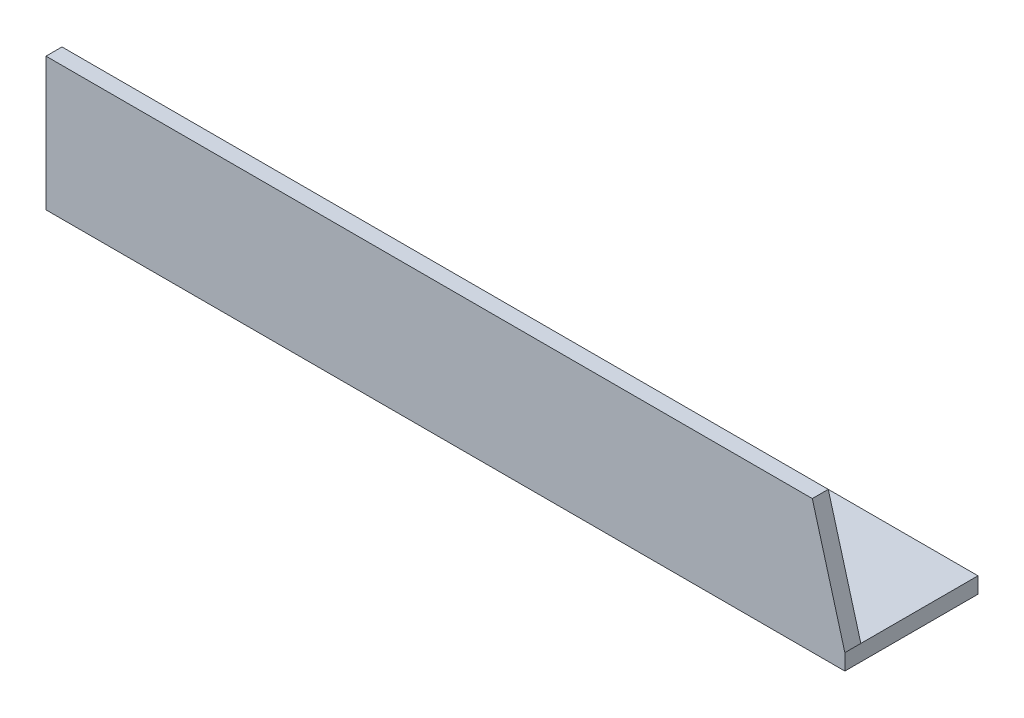
from build123d import *

# Parameters (mm, degrees)
EXTRUDE_1_DEPTH     = 300
CUT_EXTRUDE_1_DEPTH = 51


with BuildPart() as part:
    # Эскиз1 → Вытянуть-Тонкостенный1 (new body)
    with BuildSketch(Plane(origin=(0, 0, 0), x_dir=(0, 0, -1), z_dir=(1, 0, 0))):
        Polygon((0, 50), (0, 0), (50, 0), (50, 6), (6, 6), (6, 50), align=None)
    extrude(amount=EXTRUDE_1_DEPTH)

    # Эскиз2 → Вырез-Вытянуть1 (cut, through all)
    with BuildSketch(Plane.XY):
        Polygon((287.773512033, 50), (300, 50), (300, 6), align=None)
    extrude(amount=-CUT_EXTRUDE_1_DEPTH, mode=Mode.SUBTRACT)


solid = part.part
